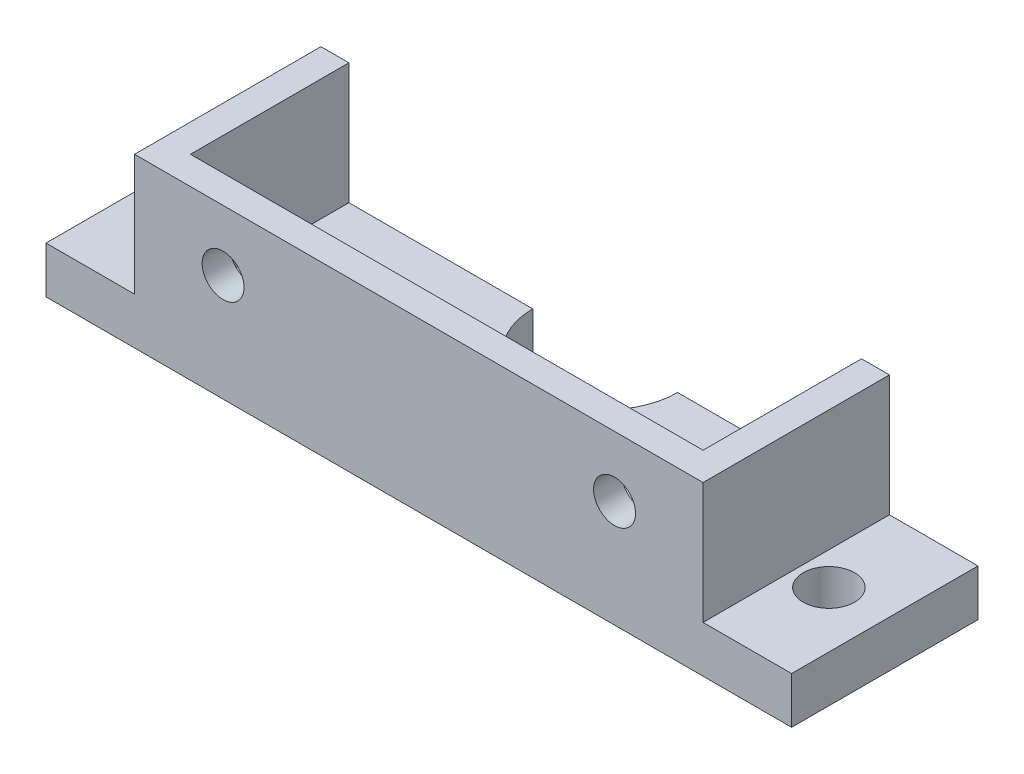
from build123d import *

# Parameters (mm, degrees)
SKETCH1_W           = 80
SKETCH1_H           = 20
BOSS_EXTRUDE1_DEPTH = 5
SKETCH2_R           = 2.75
CUT_EXTRUDE1_DEPTH  = 5
SKETCH3_W           = 61
SKETCH3_H           = 13
SKETCH3_R           = 2.25
BOSS_EXTRUDE2_DEPTH = 3
SKETCH4_W           = 3
SKETCH4_H           = 13
BOSS_EXTRUDE3_DEPTH = 17
SKETCH5_R           = 7.771284408
CUT_EXTRUDE2_DEPTH  = 17


with BuildPart() as part:
    # Sketch1 → Boss-Extrude1 (new body)
    with BuildSketch(Plane(origin=(0, 0, 0), x_dir=(1, 0, 0), z_dir=(0, 1, 0))):
        Rectangle(SKETCH1_W, SKETCH1_H)
    extrude(amount=BOSS_EXTRUDE1_DEPTH)

    # Sketch2 → Cut-Extrude1 (cut)
    with BuildSketch(Plane(origin=(0, 5, 0), x_dir=(1, 0, 0), z_dir=(0, 1, 0))):
        with Locations((-34, 0)):
            Circle(SKETCH2_R)
        with Locations((34, 0)):
            Circle(SKETCH2_R)
    extrude(amount=-CUT_EXTRUDE1_DEPTH, mode=Mode.SUBTRACT)

    # Sketch3 → Boss-Extrude2 (add)
    with BuildSketch(Plane.XY.offset(10)):
        with Locations((0, 11.5)):
            Rectangle(SKETCH3_W, SKETCH3_H)
        with Locations((-21, 11.5)):
            Circle(SKETCH3_R, mode=Mode.SUBTRACT)
        with Locations((21, 11.5)):
            Circle(SKETCH3_R, mode=Mode.SUBTRACT)
    extrude(amount=-BOSS_EXTRUDE2_DEPTH)

    # Sketch4 → Boss-Extrude3 (add)
    with BuildSketch(Plane(origin=(0, 0, 7), x_dir=(-1, 0, 0), z_dir=(0, 0, -1))):
        with Locations((-29, 11.5)):
            Rectangle(SKETCH4_W, SKETCH4_H)
        with Locations((29, 11.5)):
            Rectangle(SKETCH4_W, SKETCH4_H)
    extrude(amount=BOSS_EXTRUDE3_DEPTH)

    # Sketch5 → Cut-Extrude2 (cut)
    with BuildSketch(Plane(origin=(0, 5, 0), x_dir=(1, 0, 0), z_dir=(0, 1, 0))):
        with Locations((0, 10)):
            Circle(SKETCH5_R)
    extrude(amount=-CUT_EXTRUDE2_DEPTH, mode=Mode.SUBTRACT)


solid = part.part
